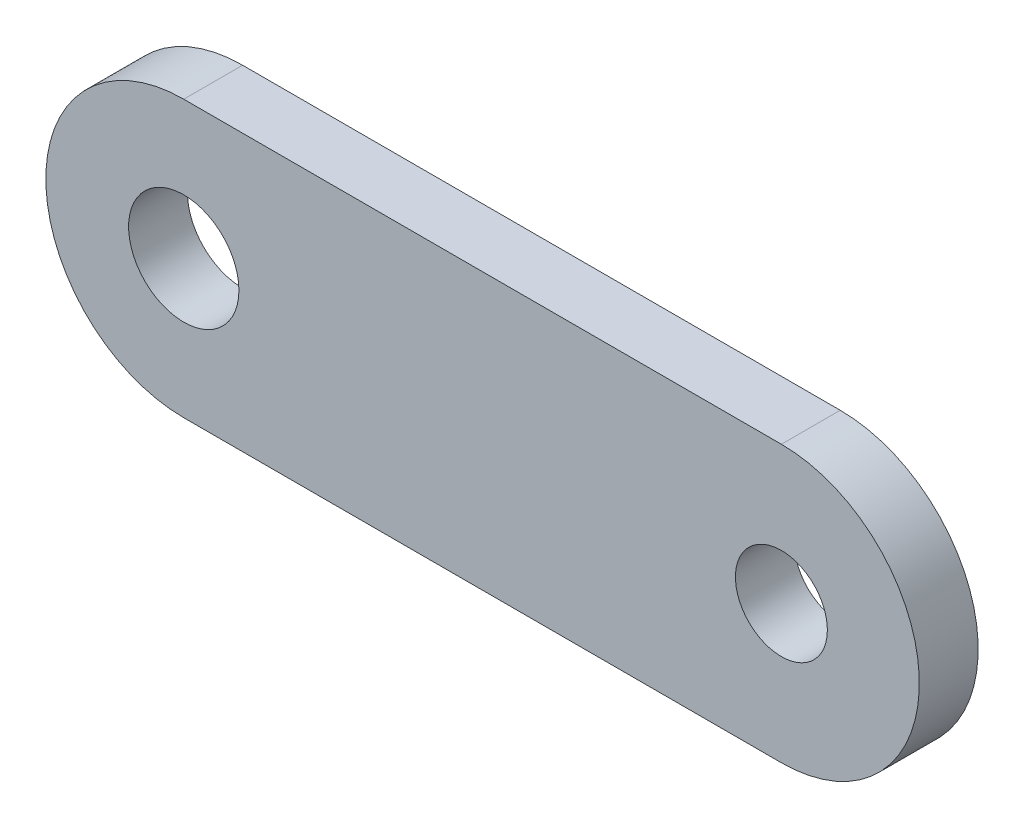
from build123d import *

# Parameters (mm, degrees)
SKETCH1_R           = 1.5875
SKETCH1_R_2         = 1.905
BOSS_EXTRUDE1_DEPTH = 1.016


with BuildPart() as part:
    # Sketch1 → Boss-Extrude1 (new body, symmetric)
    with BuildSketch(Plane.XY):
        with BuildLine():
            Line((-71.739999898, -4.7625), (-92.374999898, -4.7625))
            ThreePointArc((-92.374999898, -4.7625), (-97.137499898, 0), (-92.374999898, 4.7625))
            Line((-92.374999898, 4.7625), (-71.739999898, 4.7625))
            ThreePointArc((-71.739999898, 4.7625), (-66.977499898, 0), (-71.739999898, -4.7625))
        make_face()
        with Locations((-71.739999898, 0)):
            Circle(SKETCH1_R, mode=Mode.SUBTRACT)
        with Locations((-92.374999898, 0)):
            Circle(SKETCH1_R_2, mode=Mode.SUBTRACT)
    extrude(amount=BOSS_EXTRUDE1_DEPTH, both=True)


solid = part.part
